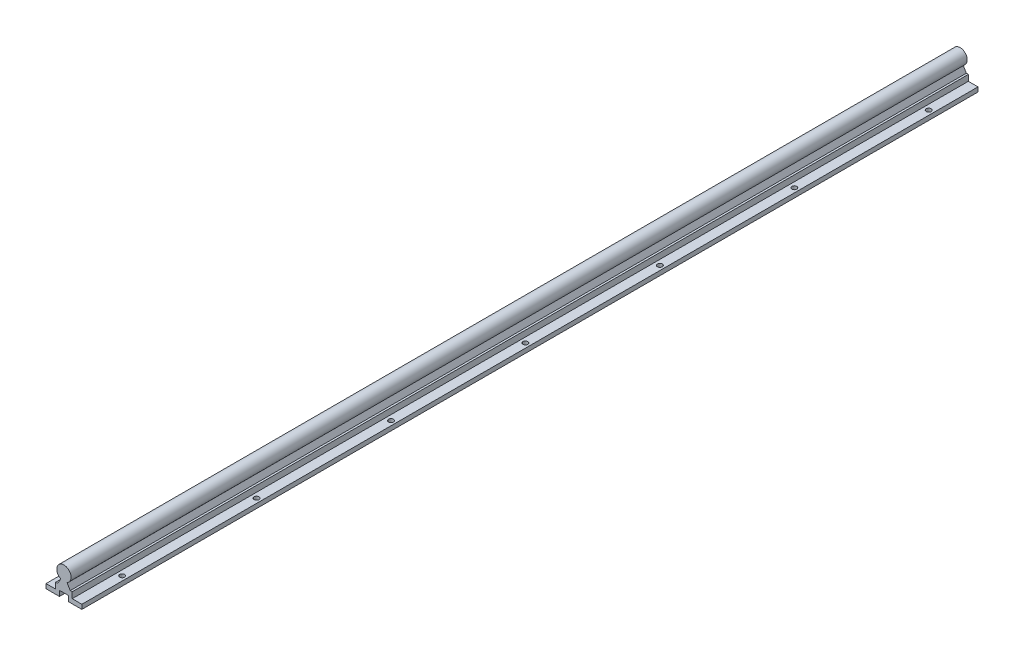
from build123d import *

# Parameters (mm, degrees)
BOSS_EXTRUDE1_DEPTH = 500
SKETCH2_R           = 2.75
CUT_EXTRUDE1_DEPTH  = 6
LPATTERN1_COUNT     = 7
LPATTERN1_PITCH     = 150


with BuildPart() as part:
    # Sketch1 → Boss-Extrude1 (new body, symmetric)
    with BuildSketch(Plane.XY):
        with BuildLine():
            Line((-7.008955797, -13.3), (-3.487119155, -7.2))
            ThreePointArc((-3.487119155, -7.2), (0, 8), (3.487119155, -7.2))
            Line((3.487119155, -7.2), (7.008955797, -13.3))
            Line((7.008955797, -13.3), (9.25, -13.3))
            Line((9.25, -13.3), (9.25, -20))
            Line((9.25, -20), (20, -20))
            Line((20, -20), (20, -25))
            Line((20, -25), (5, -25))
            Line((5, -25), (5, -19))
            Line((5, -19), (-5, -19))
            Line((-5, -19), (-5, -25))
            Line((-5, -25), (-20, -25))
            Line((-20, -25), (-20, -20))
            Line((-20, -20), (-9.25, -20))
            Line((-9.25, -20), (-9.25, -13.3))
            Line((-9.25, -13.3), (-7.008955797, -13.3))
        make_face()
    extrude(amount=BOSS_EXTRUDE1_DEPTH, both=True)

    # Sketch2 → Cut-Extrude1 (cut, through all)
    with BuildSketch(Plane(origin=(0, -20, 0), x_dir=(1, 0, 0), z_dir=(0, 1, 0))):
        with Locations(Location((15, -450, 0), (0, 0, 270))):  # turned: the seam where the file's is
            Circle(SKETCH2_R)
        with Locations(Location((-15, -450, 0), (0, 0, 270))):  # turned: the seam where the file's is
            Circle(SKETCH2_R)
    cut_extrude1 = extrude(amount=-CUT_EXTRUDE1_DEPTH, mode=Mode.SUBTRACT)

    # LPattern1: Cut-Extrude1 ×7
    with Locations(*[(0, 0, -i * LPATTERN1_PITCH) for i in range(1, LPATTERN1_COUNT)]):
        add(cut_extrude1, mode=Mode.SUBTRACT)


solid = part.part
